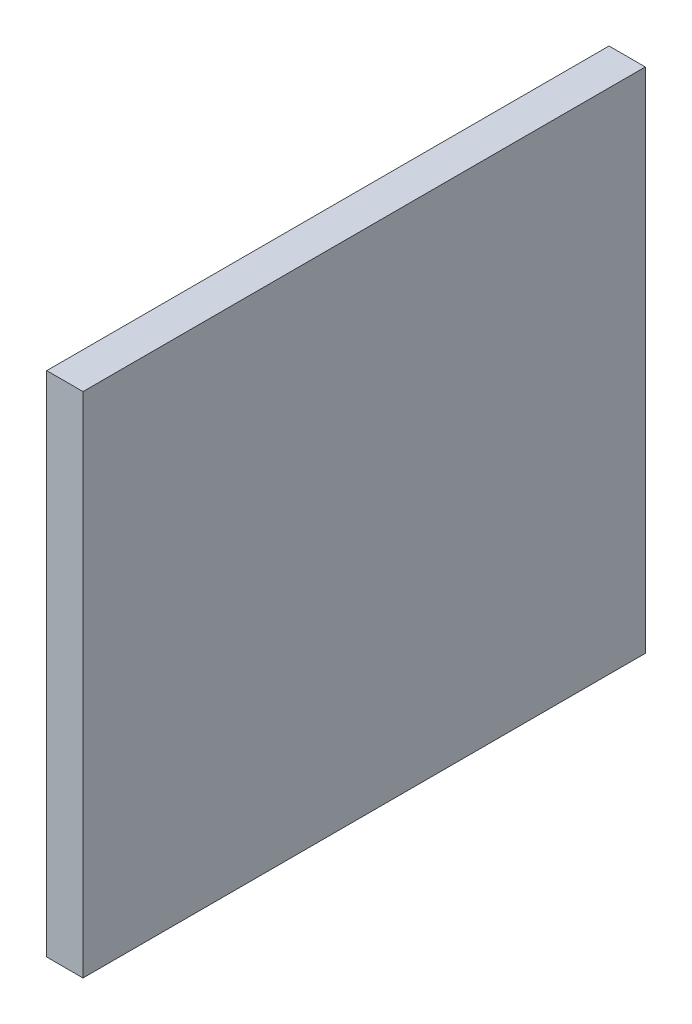
from build123d import *

# Parameters (mm, degrees)
SKETCH1_W           = 10
SKETCH1_H           = 140
BOSS_EXTRUDE1_DEPTH = 155


with BuildPart() as part:
    # Sketch1 → Boss-Extrude1 (new body)
    with BuildSketch(Plane.XY):
        with Locations((155, -70)):
            Rectangle(SKETCH1_W, SKETCH1_H)
    extrude(amount=BOSS_EXTRUDE1_DEPTH)


solid = part.part
